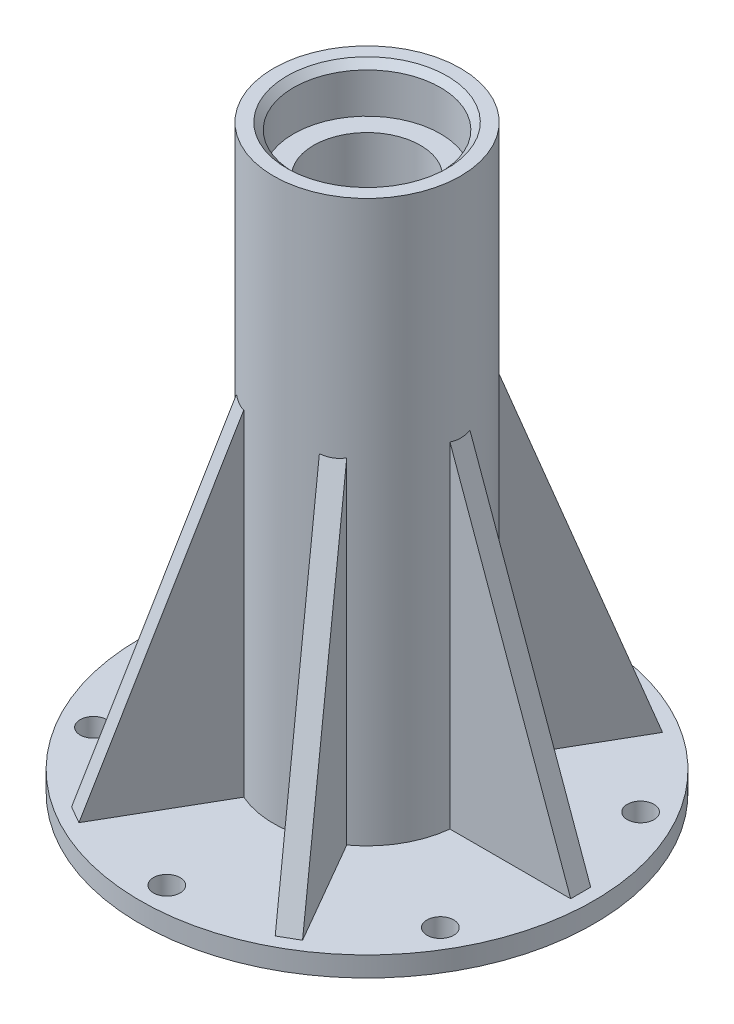
from build123d import *

# Parameters (mm, degrees)
ESQUISSE2_R                  = 2
ENL_V_MAT_EXTRU_1_DEPTH      = 97.788429061
CHANFREIN1_SIZE              = 1
NERVURE11_REACH              = 101.403
ESQUISSE5_WALL_W             = 253.94775955
ESQUISSE5_WALL_H             = 3
R_P_TITION_CIRCULAIRE1_COUNT = 6


with BuildPart() as part:
    # Esquisse1 → Révolution1 (revolve)
    with BuildSketch(Plane.XY):
        Polygon((-8, 0), (-34, 0), (-34, 3), (-19, 3), (-14, 3), (-14, 8), (-14, 87), (-11, 87), (-11, 80), (-8, 80), align=None)
    revolve(axis=Axis((0, 5.729166667, 0), (0, -1, 0)))

    # Esquisse2 → Enlèv. mat.-Extru.1 (cut, through all)
    with BuildSketch(Plane(origin=(0, 3, 0), x_dir=(1, 0, 0), z_dir=(0, 1, 0))):
        with Locations(Location((0, 30, 0), (0, 0, 180))):
            Circle(ESQUISSE2_R)
        with Locations(Location((25.980762114, 15, 0), (0, 0, 180))):
            Circle(ESQUISSE2_R)
        with Locations(Location((25.980762114, -15, 0), (0, 0, 180))):
            Circle(ESQUISSE2_R)
        with Locations(Location((0, -30, 0), (0, 0, 180))):
            Circle(ESQUISSE2_R)
        with Locations(Location((-25.980762114, -15, 0), (0, 0, 180))):
            Circle(ESQUISSE2_R)
        with Locations(Location((-25.980762114, 15, 0), (0, 0, 180))):
            Circle(ESQUISSE2_R)
    extrude(amount=-ENL_V_MAT_EXTRU_1_DEPTH, mode=Mode.SUBTRACT)

    # Chanfrein1
    chanfrein1_edges = [part.edges().sort_by_distance(p)[0] for p in [
        (11, 87, 0),
    ]]
    chamfer(chanfrein1_edges, length=CHANFREIN1_SIZE)

    # Esquisse5 wall → Nervure11 (add, up to next)
    with BuildSketch(Plane(origin=(23, 28, 0), x_dir=(0.338719468273, -0.940887411869, 0), z_dir=(0.940887411869, 0.338719468273, 0)), mode=Mode.PRIVATE) as nervure11_sk1:
        Rectangle(ESQUISSE5_WALL_W, ESQUISSE5_WALL_H)
    nervure11_tool1 = extrude(nervure11_sk1.sketch, amount=-NERVURE11_REACH, mode=Mode.PRIVATE) - part.part
    nervure11 = nervure11_tool1.solids().sort_by_distance((23, 28, 0))[0]
    add(nervure11)

    # Répétition circulaire1: Nervure11 ×6 about axis
    r_p_tition_circulaire1_axis = Axis((0, 0, 0), (0, 1, 0))
    for i in range(1, R_P_TITION_CIRCULAIRE1_COUNT):
        add(nervure11.rotate(r_p_tition_circulaire1_axis, i * 360 / R_P_TITION_CIRCULAIRE1_COUNT))


solid = part.part
